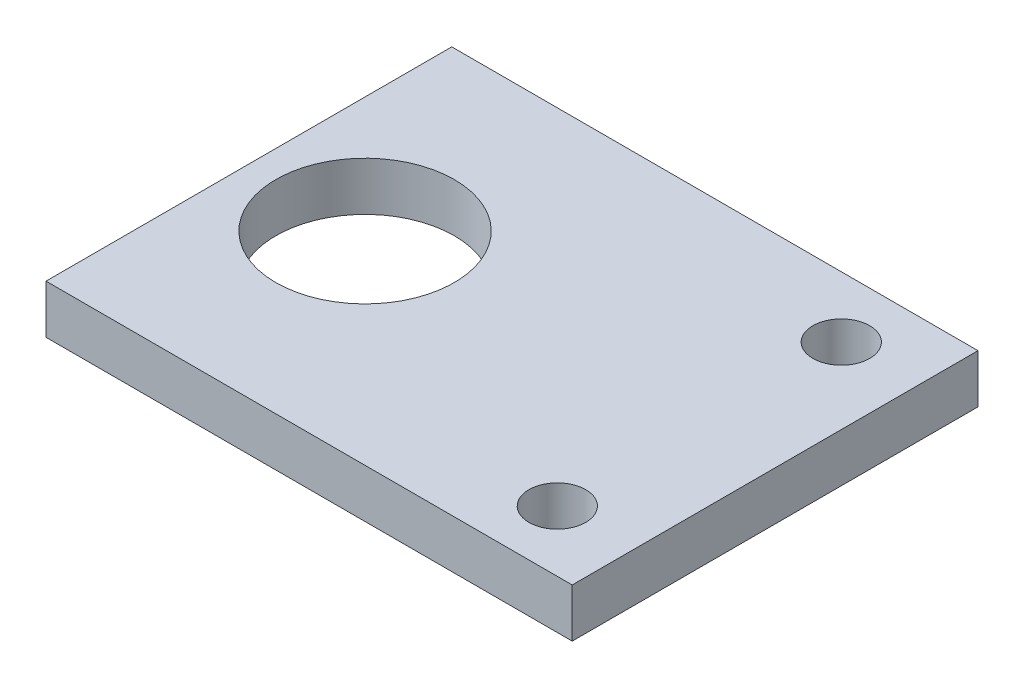
from build123d import *

# Parameters (mm, degrees)
SKETCH1_W           = 32.429536638
SKETCH1_H           = 25.007766804
SKETCH1_R           = 1.75
SKETCH1_R_2         = 5.5
BOSS_EXTRUDE1_DEPTH = 3


with BuildPart() as part:
    # Sketch1 → Boss-Extrude1 (new body)
    with BuildSketch(Plane(origin=(0, 0, 0), x_dir=(1, 0, 0), z_dir=(0, 1, 0))):
        with Locations((-9.865681564, 0)):
            Rectangle(SKETCH1_W, SKETCH1_H)
        with Locations((1.678034292, -8.75)):
            Circle(SKETCH1_R, mode=Mode.SUBTRACT)
        with Locations((1.678034292, 8.75)):
            Circle(SKETCH1_R, mode=Mode.SUBTRACT)
        with Locations((-18.921965708, 0)):
            Circle(SKETCH1_R_2, mode=Mode.SUBTRACT)
    extrude(amount=BOSS_EXTRUDE1_DEPTH)


solid = part.part
